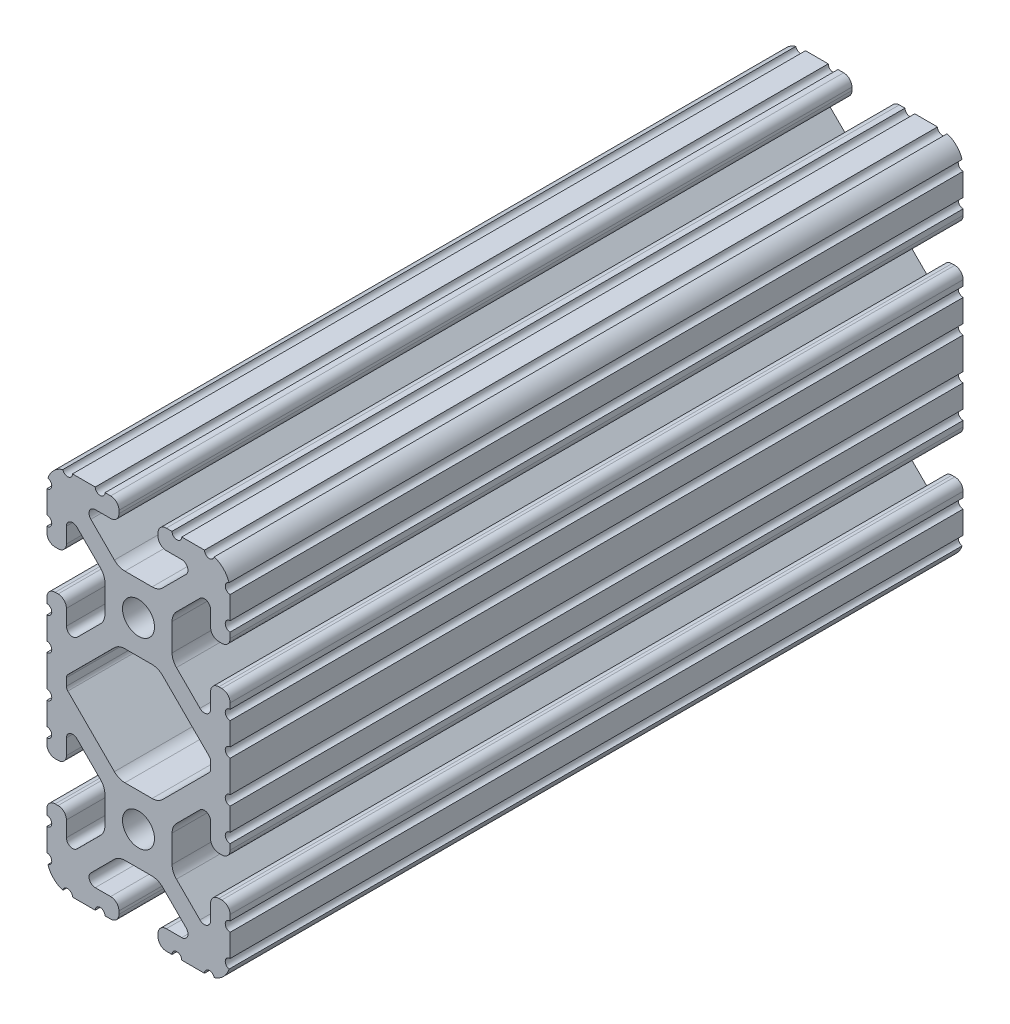
from build123d import *

# Parameters (mm, degrees)
BOSS_EXTRUDE1_DEPTH     = 76.2
SKETCH5_R               = 1.016
CUT_EXTRUDE1_DEPTH      = 77.2
CUT_EXTRUDE1_DEPTH_BACK = 77.2
BOSS_EXTRUDE2_DEPTH     = 76.2
CUT_EXTRUDE2_DEPTH      = 77.2
CUT_EXTRUDE2_DEPTH_BACK = 77.2


with BuildPart() as part:
    # Sketch4 → Boss-Extrude1 (new body, symmetric)
    with BuildSketch(Plane.XY):
        with BuildLine():
            Line((5.7912, -38.1), (14.3002, -38.1))
            ThreePointArc((14.3002, -38.1), (17.658815789, -36.708815789), (19.05, -33.3502))
            Line((19.05, -33.3502), (19.05, -24.8412))
            ThreePointArc((19.05, -24.8412), (18.544114832, -23.619885168), (17.3228, -23.114))
            Line((17.3228, -23.114), (16.7132, -23.114))
            ThreePointArc((16.7132, -23.114), (15.491885168, -23.619885168), (14.986, -24.8412))
            Line((14.986, -24.8412), (14.986, -28.046305235))
            ThreePointArc((14.986, -28.046305235), (14.189232738, -29.238751711), (12.782646215, -28.958964256))
            Line((12.782646215, -28.958964256), (7.888897763, -24.065215804))
            ThreePointArc((7.888897763, -24.065215804), (7.219915375, -23.064012907), (6.985, -21.883013566))
            Line((6.985, -21.883013566), (6.985, -19.05))
            Line((6.985, -19.05), (3.3274, -19.05))
            ThreePointArc((3.3274, -19.05), (2.352827104, -21.402827104), (0, -22.3774))
            Line((0, -22.3774), (0, -26.035))
            Line((0, -26.035), (2.833013566, -26.035))
            ThreePointArc((2.833013566, -26.035), (4.014012907, -26.269915375), (5.015215804, -26.938897763))
            Line((5.015215804, -26.938897763), (9.908964256, -31.832646215))
            ThreePointArc((9.908964256, -31.832646215), (10.188751711, -33.239232738), (8.996305235, -34.036))
            Line((8.996305235, -34.036), (5.7912, -34.036))
            ThreePointArc((5.7912, -34.036), (4.569885168, -34.541885168), (4.064, -35.7632))
            Line((4.064, -35.7632), (4.064, -36.3728))
            ThreePointArc((4.064, -36.3728), (4.569885168, -37.594114832), (5.7912, -38.1))
        make_face()
    extrude(amount=BOSS_EXTRUDE1_DEPTH, both=True)

    # Sketch5 → Cut-Extrude1 (cut, two sides)
    with BuildSketch(Plane.XY) as cut_extrude1_sk:
        with Locations((14.739477062, -38.1)):
            Circle(SKETCH5_R)
        with Locations((7.980305235, -38.1)):
            Circle(SKETCH5_R)
        with Locations((19.05, -33.789477062)):
            Circle(SKETCH5_R)
        with Locations((19.05, -27.030305235)):
            Circle(SKETCH5_R)
    extrude(amount=CUT_EXTRUDE1_DEPTH, mode=Mode.SUBTRACT)
    extrude(cut_extrude1_sk.sketch, amount=-CUT_EXTRUDE1_DEPTH_BACK, mode=Mode.SUBTRACT)

    # Mirror1: part across plane


with BuildPart() as part_1:
    add(part.part)
    add(part.part.mirror(Plane(origin=(6.985, -19.05, 76.2), x_dir=(0, 0, 1), z_dir=(0, -1, 0))))

    # Sketch6 → Boss-Extrude2 (add, symmetric)
    with BuildSketch(Plane.XY):
        with BuildLine():
            Line((19.05, -3.294522938), (19.05, 0))
            Line((19.05, 0), (13.723477062, 0))
            Line((13.723477062, 0), (13.723477062, -4.310522938))
            Line((13.723477062, -4.310522938), (18.034, -4.310522938))
            ThreePointArc((18.034, -4.310522938), (18.33157951, -3.592102448), (19.05, -3.294522938))
        make_face()
    extrude(amount=BOSS_EXTRUDE2_DEPTH, both=True)

    # Sketch7 → Cut-Extrude2 (cut, two sides)
    with BuildSketch(Plane.XY) as cut_extrude2_sk:
        with BuildLine():
            Line((7.46209003, -8.714228011), (14.68842049, -1.487897552))
            ThreePointArc((14.68842049, -1.487897552), (14.908661605, -1.158283429), (14.986, -0.769477062))
            Line((14.986, -0.769477062), (14.986, 0))
            Line((14.986, 0), (0, 0))
            Line((0, 0), (7.46209003, -8.714228011))
        make_face()
    extrude(amount=CUT_EXTRUDE2_DEPTH, mode=Mode.SUBTRACT)
    extrude(cut_extrude2_sk.sketch, amount=-CUT_EXTRUDE2_DEPTH_BACK, mode=Mode.SUBTRACT)

    # Mirror2: part across plane


with BuildPart() as part_2:
    add(part_1.part)
    add(part_1.part.mirror(Plane.ZX))

    # Mirror3: part across plane


with BuildPart() as part_3:
    add(part_2.part)
    add(part_2.part.mirror(Plane(origin=(0, 0, 0), x_dir=(0, 0, 1), z_dir=(1, 0, 0))))


solid = part_3.part
